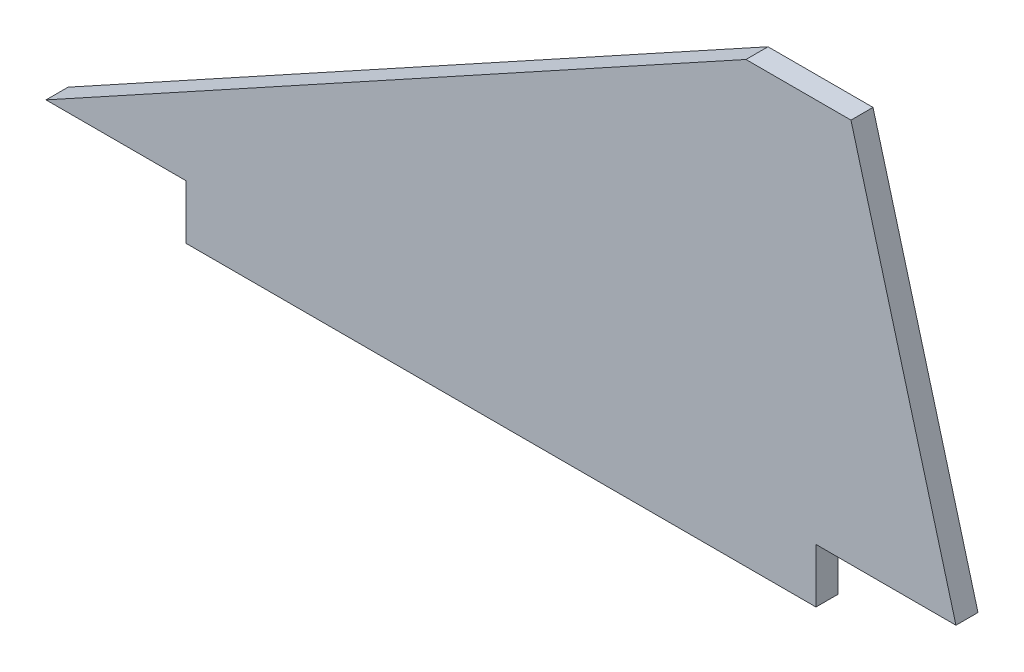
from build123d import *

# Parameters (mm, degrees)
BOSS_EXTRUDE1_DEPTH = 3.1496


with BuildPart() as part:
    # Sketch1 → Boss-Extrude1 (new body)
    with BuildSketch(Plane.XY):
        Polygon((0, 0), (20, 0), (20, -7.747), (110, -7.747), (110, 0), (130, 0), (115, 55), (100, 55), align=None)
    extrude(amount=BOSS_EXTRUDE1_DEPTH)


solid = part.part
